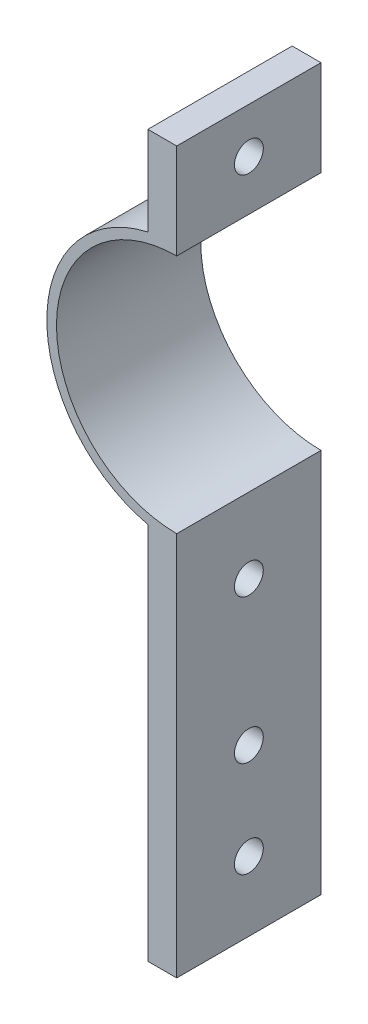
from build123d import *

# Parameters (mm, degrees)
EXTRUDE_1_DEPTH     = 15
SKETCH_2_R          = 1.5
CUT_EXTRUDE_1_DEPTH = 20


with BuildPart() as part:
    # 草图1 → 凸台-拉伸1 (new body)
    with BuildSketch(Plane.XY):
        with BuildLine():
            Line((-3, 22.405228465), (-3, 13.162446581))
            ThreePointArc((-3, 13.162446581), (-10.55343546, 8.41872912), (-13.5, 0))
            ThreePointArc((-13.5, 0), (-10.55343546, -8.41872912), (-3, -13.162446581))
            Line((-3, -13.162446581), (-3, -52.5))
            Line((-3, -52.5), (0, -52.5))
            Line((0, -52.5), (0, -12.5))
            ThreePointArc((0, -12.5), (-12.5, 0), (0, 12.5))
            Line((0, 12.5), (0, 22.405228465))
            Line((0, 22.405228465), (-3, 22.405228465))
        make_face()
    extrude(amount=EXTRUDE_1_DEPTH)

    # 草图2 → 切除-拉伸1 (cut)
    with BuildSketch(Plane.ZY.offset(3)):
        with Locations((7.5, 17.696731087)):
            Circle(SKETCH_2_R)
        with Locations((7.5, -20.291502622)):
            Circle(SKETCH_2_R)
        with Locations((7.5, -35.291502622)):
            Circle(SKETCH_2_R)
        with Locations((7.5, -45.291502622)):
            Circle(SKETCH_2_R)
    extrude(amount=-CUT_EXTRUDE_1_DEPTH, mode=Mode.SUBTRACT)


solid = part.part
